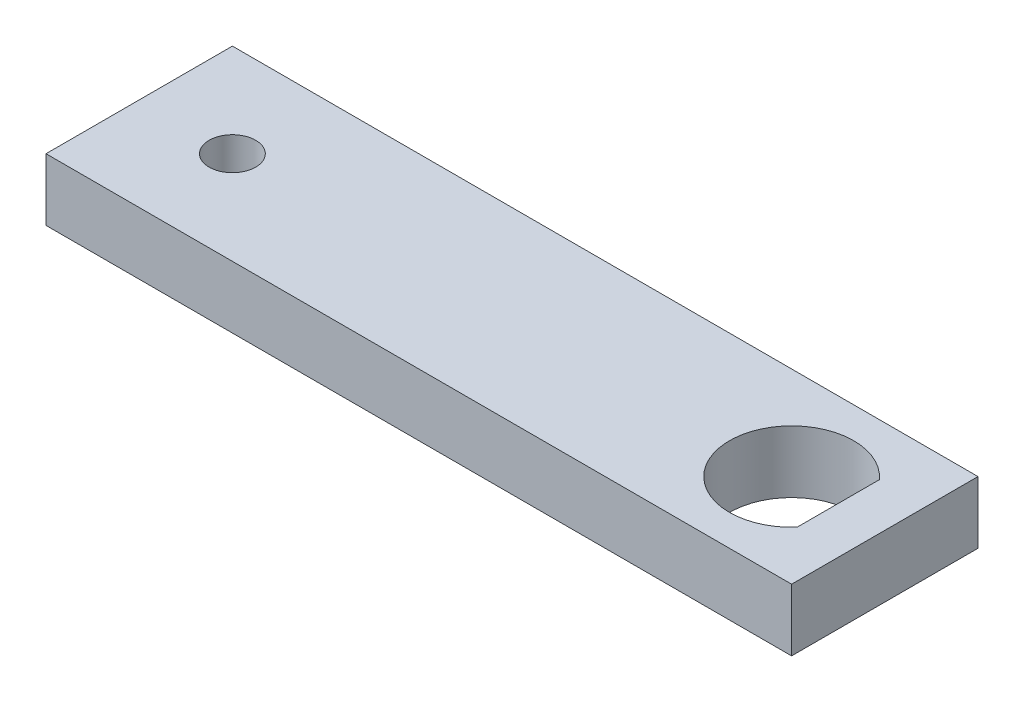
from build123d import *

# Parameters (mm, degrees)
SKETCH1_W          = 76.2
SKETCH1_H          = 6.35
BASE_EXTRUDE_DEPTH = 19.05
CUT_EXTRUDE1_DEPTH = 7.35
SKETCH3_R          = 2.38125
CUT_EXTRUDE2_DEPTH = 7.35


with BuildPart() as part:
    # Sketch1 → Base-Extrude (new body)
    with BuildSketch(Plane.XY):
        with Locations((38.1, 3.175)):
            Rectangle(SKETCH1_W, SKETCH1_H)
    extrude(amount=BASE_EXTRUDE_DEPTH)

    # Sketch2 → Cut-Extrude1 (cut, through all)
    with BuildSketch(Plane(origin=(0, 6.35, 0), x_dir=(-1, 0, 0), z_dir=(0, 1, 0))):
        with BuildLine():
            Line((-71.4375, 5.324869794), (-71.4375, 13.725130206))
            ThreePointArc((-71.4375, 13.725130206), (-60.325, 9.525), (-71.4375, 5.324869794))
        make_face()
    extrude(amount=-CUT_EXTRUDE1_DEPTH, mode=Mode.SUBTRACT)

    # Sketch3 → Cut-Extrude2 (cut, through all)
    with BuildSketch(Plane(origin=(0, 6.35, 0), x_dir=(-1, 0, 0), z_dir=(0, 1, 0))):
        with Locations((-9.525, 9.525)):
            Circle(SKETCH3_R)
    extrude(amount=-CUT_EXTRUDE2_DEPTH, mode=Mode.SUBTRACT)


solid = part.part
